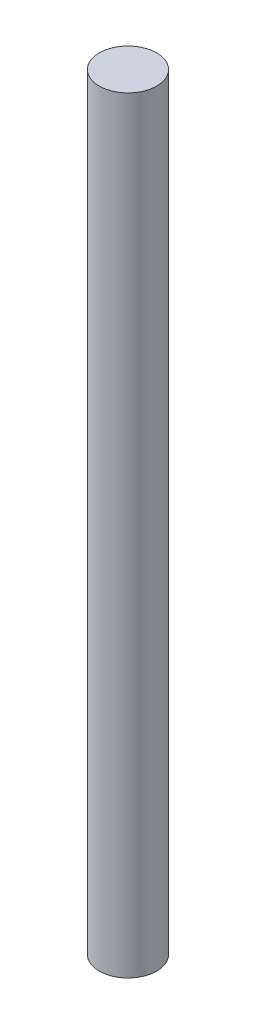
from build123d import *

# Parameters (mm, degrees)
SKETCH1_R           = 1.5
BOSS_EXTRUDE1_DEPTH = 40


with BuildPart() as part:
    # Sketch1 → Boss-Extrude1 (new body)
    with BuildSketch(Plane(origin=(0, 0, 0), x_dir=(1, 0, 0), z_dir=(0, 1, 0))):
        with Locations(Location((0, 0, 0), (0, 0, 270))):  # turned: the seam where the file's is
            Circle(SKETCH1_R)
    extrude(amount=BOSS_EXTRUDE1_DEPTH)


solid = part.part
